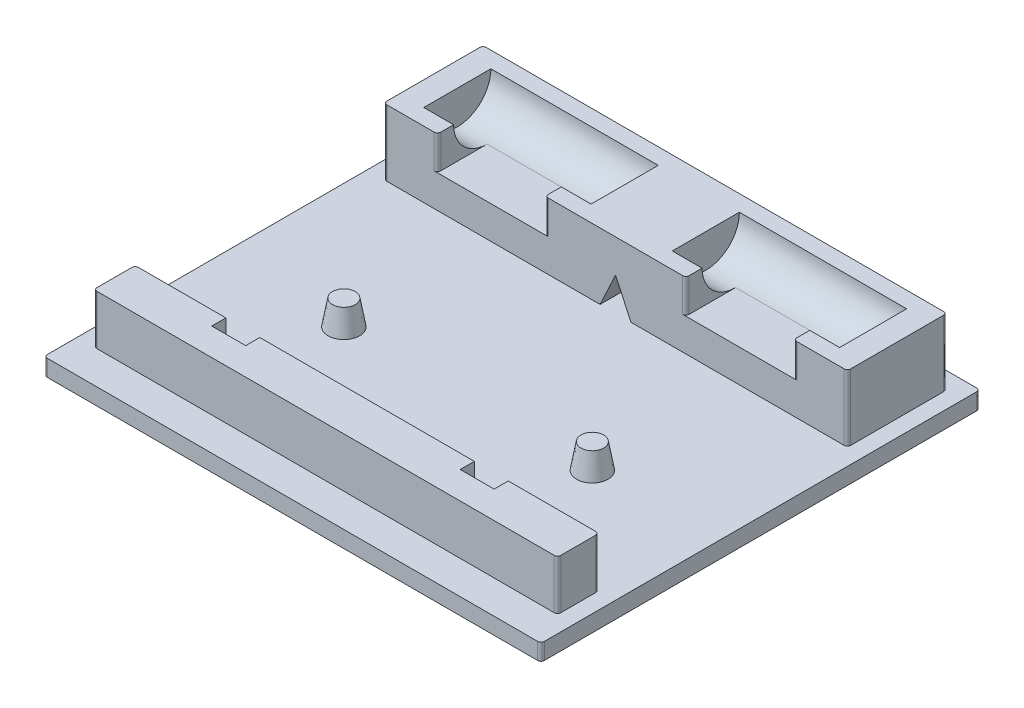
from build123d import *

# Parameters (mm, degrees)
SKETCH1_W               = 60
SKETCH1_H               = 53
BOSS_EXTRUDE1_DEPTH     = 2
SKETCH3_W               = 56
SKETCH3_H               = 12
BOSS_EXTRUDE3_DEPTH     = 10
SKETCH2_W               = 56
SKETCH2_H               = 5
BOSS_EXTRUDE2_DEPTH     = 8
CUT_EXTRUDE1_DEPTH      = 10.1
CUT_EXTRUDE1_DEPTH_BACK = 10.1
CUT_EXTRUDE2_DEPTH      = 10.1
CUT_EXTRUDE2_DEPTH_BACK = 10.1
SKETCH6_W               = 13
SKETCH6_H               = 4.05
CUT_EXTRUDE3_DEPTH      = 6
SKETCH7_R               = 1.9
BOSS_EXTRUDE4_DEPTH     = 3
BOSS_EXTRUDE4_TAPER     = 10
FILLET2_R               = 0.4
CUT_EXTRUDE4_REACH      = 53
SKETCH9_W               = 4.1
SKETCH9_H               = 1.7
CUT_EXTRUDE5_DEPTH      = 4


with BuildPart() as part:
    # Sketch1 → Boss-Extrude1 (new body)
    with BuildSketch(Plane(origin=(0, 0, 0), x_dir=(1, 0, 0), z_dir=(0, 1, 0))):
        with Locations((30, 26.5)):
            Rectangle(SKETCH1_W, SKETCH1_H)
    extrude(amount=BOSS_EXTRUDE1_DEPTH)

    # Sketch3 → Boss-Extrude3 (add)
    with BuildSketch(Plane(origin=(0, 0, 0), x_dir=(1, 0, 0), z_dir=(0, 1, 0))):
        with Locations((30, 45)):
            Rectangle(SKETCH3_W, SKETCH3_H)
    extrude(amount=BOSS_EXTRUDE3_DEPTH)

    # Sketch2 → Boss-Extrude2 (add)
    with BuildSketch(Plane(origin=(0, 0, 0), x_dir=(1, 0, 0), z_dir=(0, 1, 0))):
        with Locations((30, 6.5)):
            Rectangle(SKETCH2_W, SKETCH2_H)
    extrude(amount=BOSS_EXTRUDE2_DEPTH)

    # Sketch4 → Cut-Extrude1 (cut, two sides)
    with BuildSketch(Plane.ZY.offset(-15)) as cut_extrude1_sk:
        with BuildLine():
            Line((-40.95, 10), (-49.05, 10))
            ThreePointArc((-49.05, 10), (-45, 5.95), (-40.95, 10))
        make_face()
    extrude(amount=CUT_EXTRUDE1_DEPTH, mode=Mode.SUBTRACT)
    extrude(cut_extrude1_sk.sketch, amount=-CUT_EXTRUDE1_DEPTH_BACK, mode=Mode.SUBTRACT)

    # Sketch5 → Cut-Extrude2 (cut, two sides)
    with BuildSketch(Plane(origin=(45, 0, 0), x_dir=(0, 0, -1), z_dir=(1, 0, 0))) as cut_extrude2_sk:
        with BuildLine():
            Line((40.95, 10), (49.05, 10))
            ThreePointArc((49.05, 10), (45, 5.95), (40.95, 10))
        make_face()
    extrude(amount=CUT_EXTRUDE2_DEPTH, mode=Mode.SUBTRACT)
    extrude(cut_extrude2_sk.sketch, amount=-CUT_EXTRUDE2_DEPTH_BACK, mode=Mode.SUBTRACT)

    # Sketch6 → Cut-Extrude3 (cut)
    with BuildSketch(Plane.XY.offset(-39)):
        with Locations((15, 7.975)):
            Rectangle(SKETCH6_W, SKETCH6_H)
        with Locations((45, 7.975)):
            Rectangle(SKETCH6_W, SKETCH6_H)
    extrude(amount=-CUT_EXTRUDE3_DEPTH, mode=Mode.SUBTRACT)

    # Sketch7 → Boss-Extrude4 (add)
    with BuildSketch(Plane(origin=(0, 2, 0), x_dir=(1, 0, 0), z_dir=(0, 1, 0))):
        with Locations((15, 21.2)):
            Circle(SKETCH7_R)
        with Locations((45, 21.2)):
            Circle(SKETCH7_R)
    extrude(amount=BOSS_EXTRUDE4_DEPTH, taper=BOSS_EXTRUDE4_TAPER)

    # Fillet2
    fillet2_edges = [part.edges().sort_by_distance(p)[0] for p in [
        (58, 6, -51),
        (2, 6, -51),
        (2, 6, -39),
        (58, 6, -39),
        (2, 5, -4),
        (58, 5, -4),
        (58, 5, -9),
        (2, 5, -9),
        (0, 1, 0),
        (0, 1, -53),
        (60, 1, -53),
        (60, 1, 0),
        (8.5, 7.975, -39),
        (21.5, 7.975, -39),
        (38.5, 7.975, -39),
        (51.5, 7.975, -39),
    ]]
    fillet(fillet2_edges, radius=FILLET2_R)

    # Sketch8 → Cut-Extrude4 (cut, up to next)
    with BuildSketch(Plane(origin=(0, 0, -51), x_dir=(-1, 0, 0), z_dir=(0, 0, -1)), mode=Mode.PRIVATE) as cut_extrude4_sk1:
        Polygon((-30, 6), (-31.865230633, 2), (-28.134769367, 2), align=None)
    cut_extrude4_tool1 = extrude(cut_extrude4_sk1.sketch, amount=-CUT_EXTRUDE4_REACH, mode=Mode.PRIVATE) & part.part
    add(cut_extrude4_tool1.solids().sort_by_distance((30, 3.333333, -51))[0], mode=Mode.SUBTRACT)

    # Sketch9 → Cut-Extrude5 (cut)
    with BuildSketch(Plane(origin=(0, 8, 0), x_dir=(1, 0, 0), z_dir=(0, 1, 0))):
        with Locations((15, 8.15)):
            Rectangle(SKETCH9_W, SKETCH9_H)
        with Locations((45, 8.15)):
            Rectangle(SKETCH9_W, SKETCH9_H)
    extrude(amount=-CUT_EXTRUDE5_DEPTH, mode=Mode.SUBTRACT)


solid = part.part
